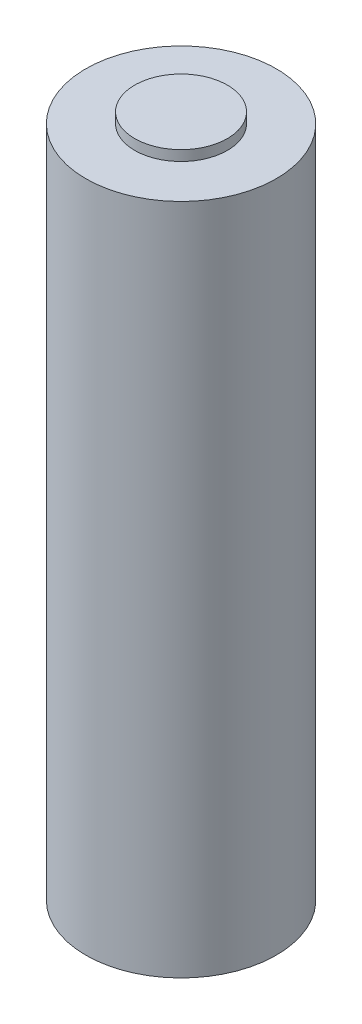
from build123d import *

# Parameters (mm, degrees)
SKETCH1_R           = 9.25
BOSS_EXTRUDE1_DEPTH = 65.3
SKETCH2_R           = 4.5
BOSS_EXTRUDE2_DEPTH = 1


with BuildPart() as part:
    # Sketch1 → Boss-Extrude1 (new body)
    with BuildSketch(Plane(origin=(0, 0, 0), x_dir=(1, 0, 0), z_dir=(0, 1, 0))):
        Circle(SKETCH1_R)
    extrude(amount=BOSS_EXTRUDE1_DEPTH)

    # Sketch2 → Boss-Extrude2 (add)
    with BuildSketch(Plane(origin=(0, 65.3, 0), x_dir=(1, 0, 0), z_dir=(0, 1, 0))):
        Circle(SKETCH2_R)
    extrude(amount=BOSS_EXTRUDE2_DEPTH)


solid = part.part
